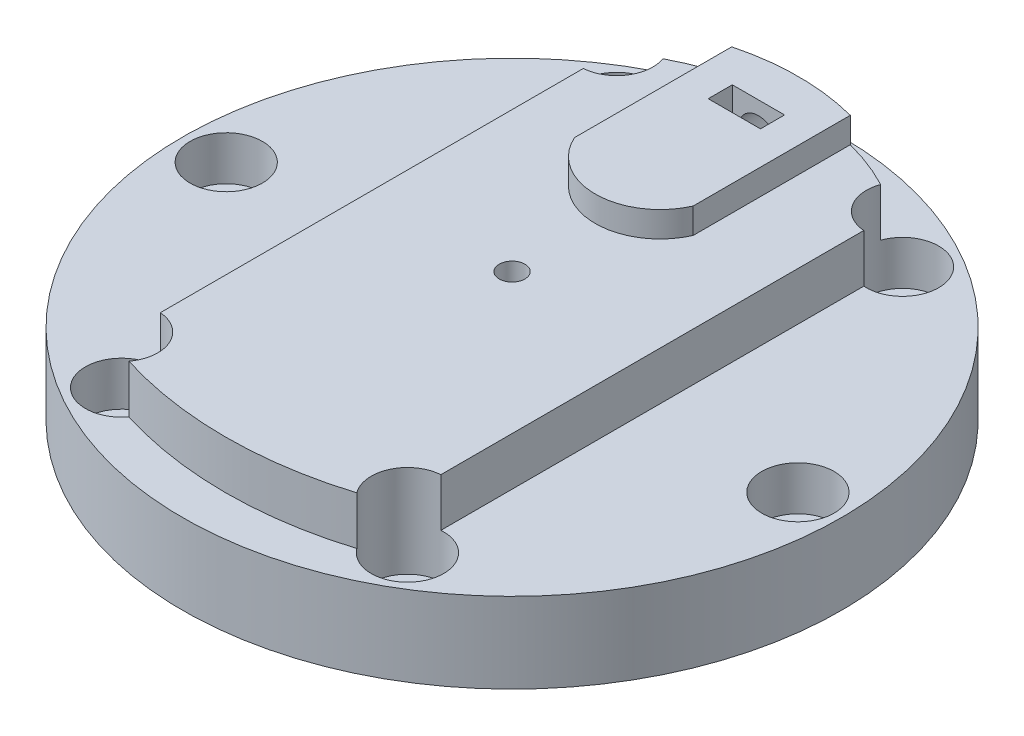
from build123d import *

# Parameters (mm, degrees)
BOSS_EXTRUDE1_DEPTH  = 6
SKETCH3_W            = 26.265732208
SKETCH3_H            = 53.5
CUT_EXTRUDE2_DEPTH   = 6
BOSS_EXTRUDE2_DEPTH  = 3.175
CUT_EXTRUDE3_DEPTH   = 9.175
SKETCH5_W            = 6.5
SKETCH5_H            = 3
CUT_EXTRUDE4_DEPTH   = 6.95
SKETCH6_R            = 2.5
CUT_EXTRUDE5_DEPTH   = 10
M3_CLEARANCE_HOLE1_D = 3.2
SKETCH17_R           = 41
BOSS_EXTRUDE3_DEPTH  = 10
SKETCH18_R           = 2.5
CUT_EXTRUDE6_DEPTH   = 5
SKETCH19_R           = 4.5
CUT_EXTRUDE7_DEPTH   = 11.5
SKETCH20_R           = 2.706261539
SKETCH20_R_2         = 3.316969597
CUT_EXTRUDE8_DEPTH   = 6


with BuildPart() as part:
    # Sketch1 → Boss-Extrude1 (new body)
    with BuildSketch(Plane(origin=(0, 0, 0), x_dir=(1, 0, 0), z_dir=(0, 1, 0))):
        with BuildLine():
            Line((-21.25, 28.5), (-21.25, -28.5))
            ThreePointArc((-21.25, -28.5), (0, -33.5), (21.25, -28.5))
            Line((21.25, -28.5), (21.25, 28.5))
            Line((21.25, 28.5), (-21.25, 28.5))
        make_face()
        with BuildLine():
            Line((-17.45, 32), (-17.45, 28.5))
            Line((-17.45, 28.5), (17.45, 28.5))
            Line((17.45, 28.5), (17.45, 32))
            ThreePointArc((17.45, 32), (0, 37.8), (-17.45, 32))
        make_face()
    extrude(amount=BOSS_EXTRUDE1_DEPTH)

    # Sketch3 → Cut-Extrude2 (cut)
    with BuildSketch(Plane.XZ):
        with Locations((-30.582866104, -1.75)):
            Rectangle(SKETCH3_W, SKETCH3_H)
        with Locations((30.582866104, -1.75)):
            Rectangle(SKETCH3_W, SKETCH3_H)
    extrude(amount=-CUT_EXTRUDE2_DEPTH, mode=Mode.SUBTRACT)

    # Sketch2 → Boss-Extrude2 (add)
    with BuildSketch(Plane(origin=(0, 6, 0), x_dir=(1, 0, 0), z_dir=(0, 1, 0))):
        with BuildLine():
            Line((-7.375, 17.3), (-7.375, 37.8))
            Line((-7.375, 37.8), (7.375, 37.8))
            Line((7.375, 37.8), (7.375, 17.3))
            ThreePointArc((7.375, 17.3), (0, 12.5), (-7.375, 17.3))
        make_face()
    extrude(amount=BOSS_EXTRUDE2_DEPTH)

    # Sketch4 → Cut-Extrude3 (cut)
    with BuildSketch(Plane.XZ):
        with BuildLine():
            Line((17.45, -32), (17.45, -50.042511561))
            Line((17.45, -50.042511561), (-17.45, -50.042511561))
            Line((-17.45, -50.042511561), (-17.45, -32))
            ThreePointArc((-17.45, -32), (0, -37.8), (17.45, -32))
        make_face()
    extrude(amount=-CUT_EXTRUDE3_DEPTH, mode=Mode.SUBTRACT)

    # Sketch5 → Cut-Extrude4 (cut)
    with BuildSketch(Plane(origin=(0, 9.175, 0), x_dir=(1, 0, 0), z_dir=(0, 1, 0))):
        with Locations((0, 31.3)):
            Rectangle(SKETCH5_W, SKETCH5_H)
    extrude(amount=-CUT_EXTRUDE4_DEPTH, mode=Mode.SUBTRACT)

    # Sketch6 → Cut-Extrude5 (cut)
    with BuildSketch(Plane(origin=(0, 9.175, -37.8), x_dir=(-1, 0, 0), z_dir=(0, 0, -1))):
        with Locations((0, -4.2)):
            Circle(SKETCH6_R)
    extrude(amount=-CUT_EXTRUDE5_DEPTH, mode=Mode.SUBTRACT)

    # M3 Clearance Hole1 (through all)
    with Locations(Plane(origin=(0, 0, 0), x_dir=(-1, 0, 0), z_dir=(0, -1, 0))):
        with Locations((0, 2.15)):
            Hole(M3_CLEARANCE_HOLE1_D / 2)

    # Sketch17 → Boss-Extrude3 (add)
    with BuildSketch(Plane.XZ):
        with Locations((0, -2.15)):
            Circle(SKETCH17_R)
    extrude(amount=BOSS_EXTRUDE3_DEPTH)

    # Sketch18 → Cut-Extrude6 (cut)
    with BuildSketch(Plane.XZ.offset(10)):
        with Locations((17.78, -32.945863359)):
            Circle(SKETCH18_R)
        with Locations((35.56, -2.15)):
            Circle(SKETCH18_R)
        with Locations((17.78, 28.645863359)):
            Circle(SKETCH18_R)
        with Locations((-17.78, -32.945863359)):
            Circle(SKETCH18_R)
        with Locations((-35.56, -2.15)):
            Circle(SKETCH18_R)
        with Locations((-17.78, 28.645863359)):
            Circle(SKETCH18_R)
    extrude(amount=-CUT_EXTRUDE6_DEPTH, mode=Mode.SUBTRACT)

    # Sketch19 → Cut-Extrude7 (cut)
    with BuildSketch(Plane(origin=(0, 6, 0), x_dir=(1, 0, 0), z_dir=(0, 1, 0))):
        with Locations((-17.78, 32.945863359)):
            Circle(SKETCH19_R)
        with Locations((17.78, 32.945863359)):
            Circle(SKETCH19_R)
        with Locations((35.56, 2.15)):
            Circle(SKETCH19_R)
        with Locations((17.78, -28.645863359)):
            Circle(SKETCH19_R)
        with Locations((-17.78, -28.645863359)):
            Circle(SKETCH19_R)
        with Locations((-35.56, 2.15)):
            Circle(SKETCH19_R)
    extrude(amount=-CUT_EXTRUDE7_DEPTH, mode=Mode.SUBTRACT)

    # Sketch20 → Cut-Extrude8 (cut)
    with BuildSketch(Plane(origin=(0, 6, 0), x_dir=(1, 0, 0), z_dir=(0, 1, 0))):
        with Locations((-20.581445068, -26.580263628)):
            Circle(SKETCH20_R)
        with Locations((20.21362745, -26.580263628)):
            Circle(SKETCH20_R_2)
    extrude(amount=-CUT_EXTRUDE8_DEPTH, mode=Mode.SUBTRACT)


solid = part.part
